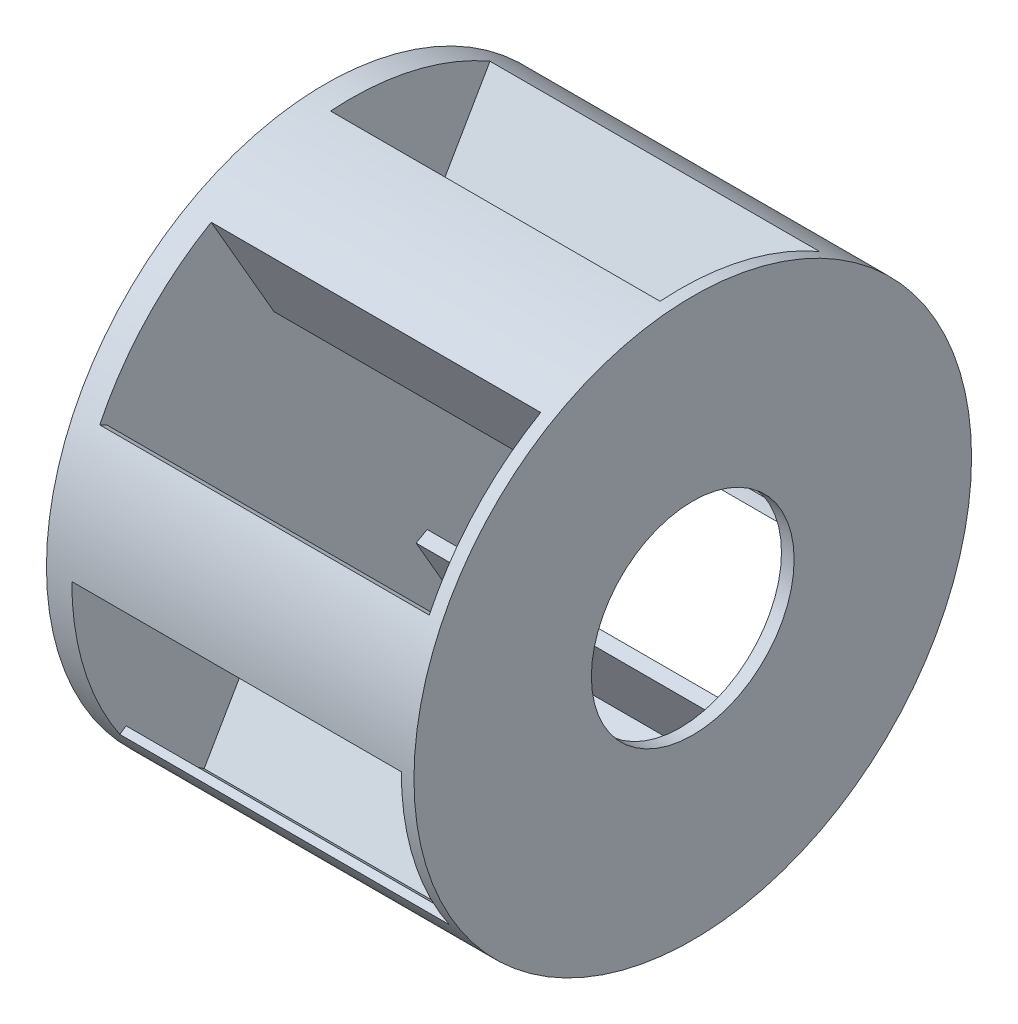
from build123d import *
from build123d.topology import SkipClean

# Parameters (mm, degrees)
SKETCH1_R           = 5.5
BOSS_EXTRUDE1_DEPTH = 0.5
BOSS_EXTRUDE2_DEPTH = 6.5
CIRPATTERN1_COUNT   = 6
SKETCH3_R           = 5.5
SKETCH3_R_2         = 2
BOSS_EXTRUDE3_DEPTH = 0.25
SKETCH4_R           = 1.5
SKETCH4_R_2         = 0.75
BOSS_EXTRUDE4_DEPTH = 2.5


with BuildPart() as part:
    # Sketch1 → Boss-Extrude1 (new body)
    with BuildSketch(Plane(origin=(0, 0, 0), x_dir=(0, 0, -1), z_dir=(1, 0, 0))):
        Circle(SKETCH1_R)
    extrude(amount=BOSS_EXTRUDE1_DEPTH)

    # Sketch2 → Boss-Extrude2 (add)
    with BuildSketch(Plane(origin=(0.5, 0, 0), x_dir=(0, 0, -1), z_dir=(1, 0, 0))):
        with BuildLine():
            Line((-5.5, 0), (-3.02, 0))
            Line((-3.02, 0), (-3.02, 0.25))
            Line((-3.02, 0.25), (-5.344155686, 0.25))
            ThreePointArc((-5.344155686, 0.25), (-5.184805145, 1.319202641), (-4.813771652, 2.334545455))
            Line((-4.813771652, 2.334545455), (-4.948737213, 2.4))
            ThreePointArc((-4.948737213, 2.4), (-5.360412982, 1.231248417), (-5.5, 0))
        make_face()
    boss_extrude2 = extrude(amount=BOSS_EXTRUDE2_DEPTH)

    # CirPattern1: Boss-Extrude2 ×6 about axis
    with SkipClean():  # keep this step's faces unmerged: merging them makes the solid invalid here
        cirpattern1_axis = Axis((0, 0, 0), (1, 0, 0))
        for i in range(1, CIRPATTERN1_COUNT):
            add(boss_extrude2.rotate(cirpattern1_axis, i * 360 / CIRPATTERN1_COUNT))

    # Sketch3 → Boss-Extrude3 (add)
    with BuildSketch(Plane(origin=(7, 0, 0), x_dir=(0, 0, -1), z_dir=(1, 0, 0))):
        Circle(SKETCH3_R)
        Circle(SKETCH3_R_2, mode=Mode.SUBTRACT)
    extrude(amount=BOSS_EXTRUDE3_DEPTH)

    # Sketch4 → Boss-Extrude4 (add)
    with SkipClean():  # keep this step's faces unmerged: merging them makes the solid invalid here
        with BuildSketch(Plane.ZY):
            with Locations(Location((0, 0, 0), (0, 0, 180))):  # turned: the seam where the file's is
                Circle(SKETCH4_R)
            Circle(SKETCH4_R_2, mode=Mode.SUBTRACT)
        extrude(amount=BOSS_EXTRUDE4_DEPTH)


solid = part.part
